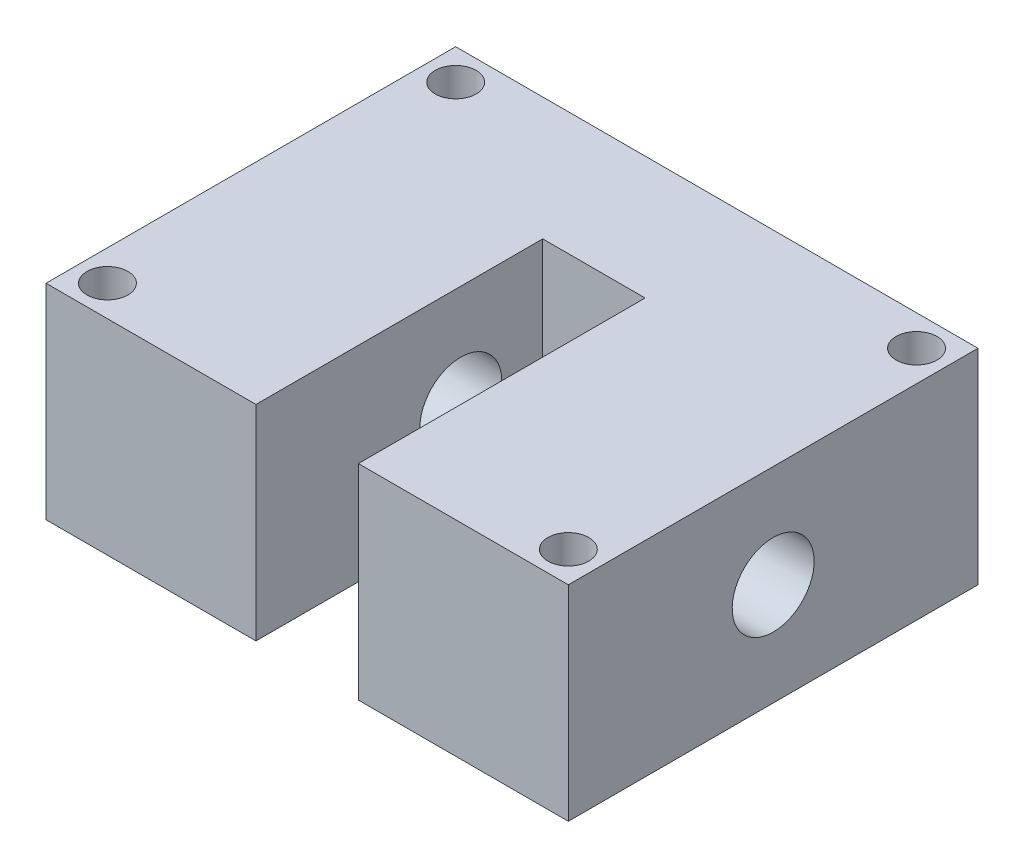
from build123d import *

# Parameters (mm, degrees)
SKETCH_1_W               = 51
SKETCH_1_H               = 20
EXTRUDE_1_DEPTH          = 20
SKETCH_2_W               = 10
SKETCH_2_H               = 20
CUT_EXTRUDE_1_DEPTH      = 28
SKETCH_3_R               = 4
CUT_EXTRUDE_2_DEPTH      = 1
CUT_EXTRUDE_2_DEPTH_BACK = 52
SKETCH_4_R               = 2
CUT_EXTRUDE_3_DEPTH      = 21


with BuildPart() as part:
    # 草图1 → 凸台-拉伸1 (new body, symmetric)
    with BuildSketch(Plane.XY):
        Rectangle(SKETCH_1_W, SKETCH_1_H)
    extrude(amount=EXTRUDE_1_DEPTH, both=True)

    # 草图2 → 切除-拉伸1 (cut)
    with BuildSketch(Plane.XY.offset(20)):
        Rectangle(SKETCH_2_W, SKETCH_2_H)
    extrude(amount=-CUT_EXTRUDE_1_DEPTH, mode=Mode.SUBTRACT)

    # 草图3 → 切除-拉伸2 (cut, two sides)
    with BuildSketch(Plane.ZY.offset(25.5)) as cut_extrude_2_sk:
        Circle(SKETCH_3_R)
    extrude(amount=CUT_EXTRUDE_2_DEPTH, mode=Mode.SUBTRACT)
    extrude(cut_extrude_2_sk.sketch, amount=-CUT_EXTRUDE_2_DEPTH_BACK, mode=Mode.SUBTRACT)

    # 草图4 → 切除-拉伸3 (cut, through all)
    with BuildSketch(Plane(origin=(0, 10, 0), x_dir=(1, 0, 0), z_dir=(0, 1, 0))):
        with Locations((-22.5, 17)):
            Circle(SKETCH_4_R)
        with Locations((22.5, -17)):
            Circle(SKETCH_4_R)
        with Locations((22.5, 17)):
            Circle(SKETCH_4_R)
        with Locations((-22.5, -17)):
            Circle(SKETCH_4_R)
    extrude(amount=-CUT_EXTRUDE_3_DEPTH, mode=Mode.SUBTRACT)


solid = part.part
